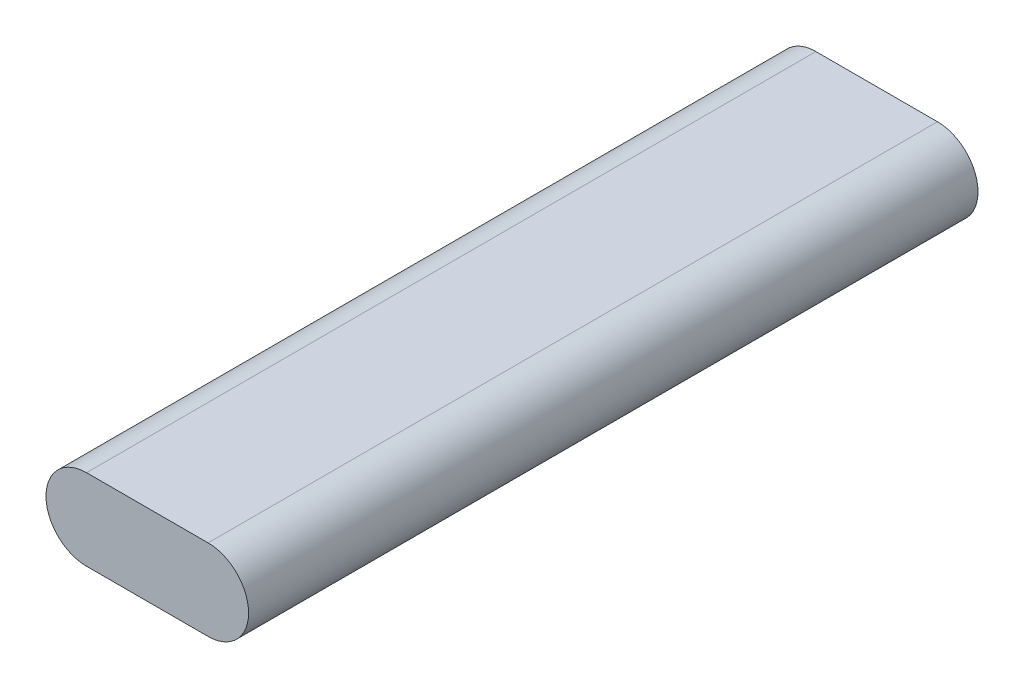
from build123d import *

# Parameters (mm, degrees)
RESSALTO_EXTRUS_O1_DEPTH = 45


with BuildPart() as part:
    # Esboço1 → Ressalto-extrusão1 (new body, symmetric)
    with BuildSketch(Plane.XY):
        with BuildLine():
            Line((-7.5, 5), (7.5, 5))
            ThreePointArc((7.5, 5), (12.5, 0), (7.5, -5))
            Line((7.5, -5), (-7.5, -5))
            ThreePointArc((-7.5, -5), (-12.5, 0), (-7.5, 5))
        make_face()
    extrude(amount=RESSALTO_EXTRUS_O1_DEPTH, both=True)


solid = part.part
